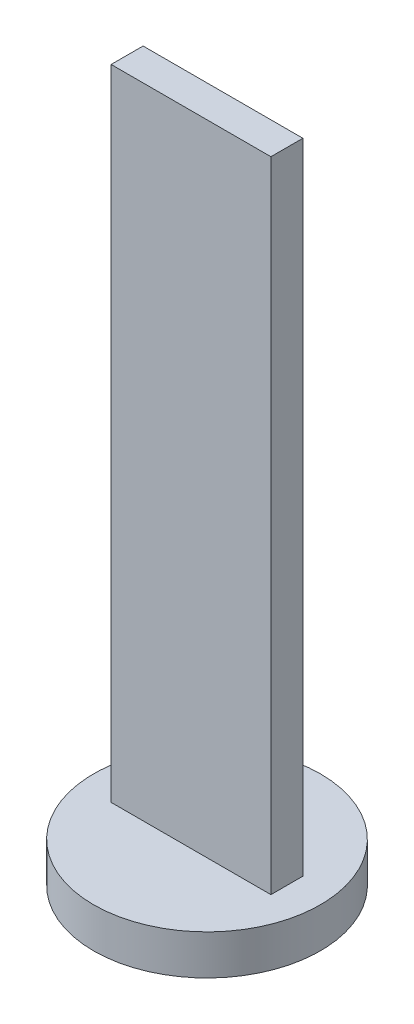
from build123d import *

# Parameters (mm, degrees)
SKETCH1_W           = 1
SKETCH1_H           = 4
BOSS_EXTRUDE1_DEPTH = 0.1
SKETCH3_R           = 0.709901951
BOSS_EXTRUDE3_DEPTH = 0.25


with BuildPart() as part:
    # Sketch1 → Boss-Extrude1 (new body, symmetric)
    with BuildSketch(Plane.XY):
        Rectangle(SKETCH1_W, SKETCH1_H)
    extrude(amount=BOSS_EXTRUDE1_DEPTH, both=True)

    # Sketch3 → Boss-Extrude3 (add)
    with BuildSketch(Plane.XZ.offset(2)):
        Circle(SKETCH3_R)
    extrude(amount=BOSS_EXTRUDE3_DEPTH)


solid = part.part
